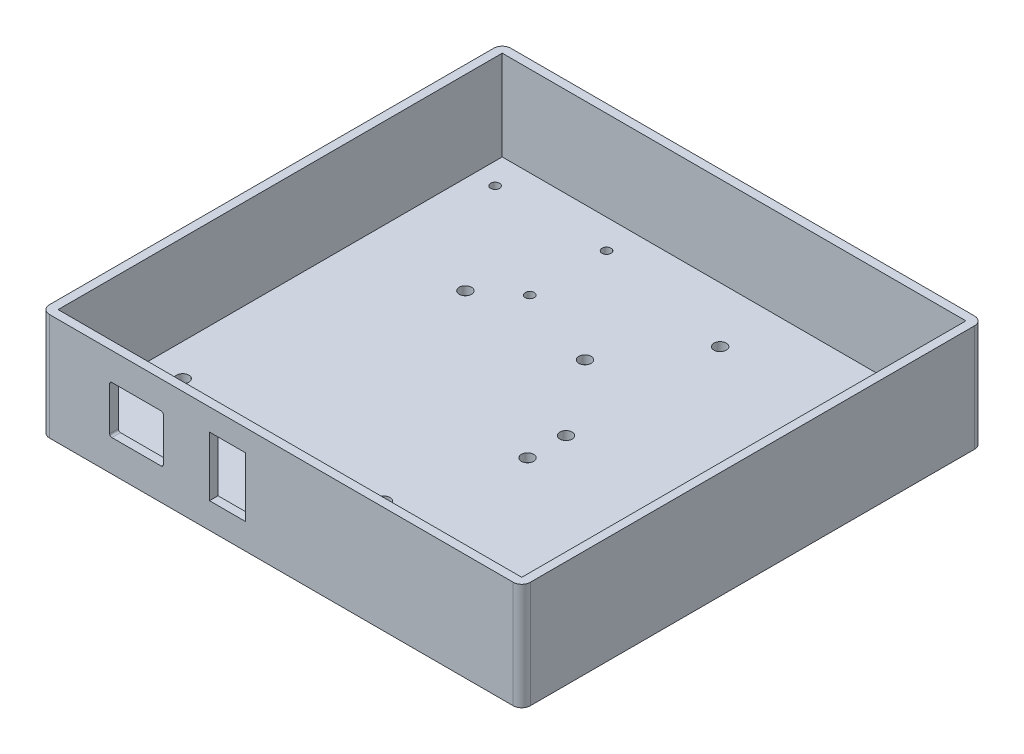
from build123d import *

# Parameters (mm, degrees)
SKETCH1_W           = 108.34
SKETCH1_H           = 103.78
BOSS_EXTRUDE1_DEPTH = 4
SKETCH2_W           = 112.34
SKETCH2_H           = 107.78
SKETCH2_W_2         = 108.34
SKETCH2_H_2         = 103.78
BOSS_EXTRUDE2_DEPTH = 25
SKETCH4_W           = 11.12
SKETCH4_H           = 9.75
CUT_EXTRUDE1_DEPTH  = 2
FILLET1_R           = 2
SKETCH5_R           = 1.4375
SKETCH5_R_2         = 1.05
CUT_EXTRUDE2_DEPTH  = 2
SKETCH6_W           = 8.4
SKETCH6_H           = 13.9
CUT_EXTRUDE3_DEPTH  = 2


with BuildPart() as part:
    # Sketch1 → Boss-Extrude1 (new body)
    with BuildSketch(Plane(origin=(0, 878.628416044, 0), x_dir=(1, 0, 0), z_dir=(0, 1, 0))):
        with Locations((715.681242052, -1282.120951231)):
            Rectangle(SKETCH1_W, SKETCH1_H)
    extrude(amount=-BOSS_EXTRUDE1_DEPTH)

    # Sketch5 → Cut-Extrude2 (cut)
    with BuildSketch(Plane(origin=(0, 878.628416044, 0), x_dir=(1, 0, 0), z_dir=(0, 1, 0))):
        with Locations(Location((684.291242052, -1261.620951231, 0), (0, 0, 270))):
            Circle(SKETCH5_R)
        with Locations(Location((666.521242052, -1236.910951231, 0), (0, 0, 270))):
            Circle(SKETCH5_R_2)
        with Locations(Location((692.681242052, -1237.030951231, 0), (0, 0, 270))):
            Circle(SKETCH5_R_2)
        with Locations(Location((692.681242052, -1254.970951231, 0), (0, 0, 270))):
            Circle(SKETCH5_R_2)
        with Locations(Location((712.231242052, -1261.620951231, 0), (0, 0, 270))):
            Circle(SKETCH5_R)
        with Locations(Location((725.351242052, -1243.160951231, 0), (0, 0, 270))):
            Circle(SKETCH5_R)
        with Locations(Location((761.351242052, -1243.160951231, 0), (0, 0, 270))):
            Circle(SKETCH5_R)
        with Locations(Location((725.351242052, -1279.160951231, 0), (0, 0, 270))):
            Circle(SKETCH5_R)
        with Locations(Location((761.351242052, -1279.160951231, 0), (0, 0, 270))):
            Circle(SKETCH5_R)
        with Locations(Location((761.351242052, -1288.160951231, 0), (0, 0, 270))):
            Circle(SKETCH5_R)
        with Locations(Location((725.351242052, -1288.160951231, 0), (0, 0, 270))):
            Circle(SKETCH5_R)
        with Locations(Location((761.351242052, -1324.160951231, 0), (0, 0, 270))):
            Circle(SKETCH5_R)
        with Locations(Location((725.351242052, -1324.160951231, 0), (0, 0, 270))):
            Circle(SKETCH5_R)
        with Locations(Location((717.311242052, -1313.690951231, 0), (0, 0, 270))):
            Circle(SKETCH5_R)
        with Locations(Location((669.051242052, -1312.420951231, 0), (0, 0, 270))):
            Circle(SKETCH5_R)
    extrude(amount=-CUT_EXTRUDE2_DEPTH, mode=Mode.SUBTRACT)


with BuildPart() as body_2:
    # Sketch2 → Boss-Extrude2 (new body)
    with BuildSketch(Plane(origin=(0, 874.628416044, 0), x_dir=(1, 0, 0), z_dir=(0, 1, 0))):
        with Locations((715.681242052, -1282.120951231)):
            Rectangle(SKETCH2_W, SKETCH2_H)
        with Locations((715.681242052, -1282.120951231)):
            Rectangle(SKETCH2_W_2, SKETCH2_H_2, mode=Mode.SUBTRACT)
    extrude(amount=BOSS_EXTRUDE2_DEPTH)

    # Sketch4 → Cut-Extrude1 (cut)
    with BuildSketch(Plane.XY.offset(1336.010951231)):
        with BuildLine():
            Line((687.591242052, 893.168416044), (676.071242052, 893.168416044))
            ThreePointArc((676.071242052, 893.168416044), (675.717688661, 893.021969435), (675.571242052, 892.668416044))
            Line((675.571242052, 892.668416044), (675.571242052, 882.518416044))
            ThreePointArc((675.571242052, 882.518416044), (675.717688661, 882.164862654), (676.071242052, 882.018416044))
            Line((676.071242052, 882.018416044), (687.591242052, 882.018416044))
            ThreePointArc((687.591242052, 882.018416044), (687.944795443, 882.164862654), (688.091242052, 882.518416044))
            Line((688.091242052, 882.518416044), (688.091242052, 892.668416044))
            ThreePointArc((688.091242052, 892.668416044), (687.944795443, 893.021969435), (687.591242052, 893.168416044))
        make_face()
        with Locations((681.831242052, 887.593416044)):
            Rectangle(SKETCH4_W, SKETCH4_H, mode=Mode.SUBTRACT)
        with Locations((681.831242052, 887.593416044)):
            Rectangle(SKETCH4_W, SKETCH4_H)
    extrude(amount=-CUT_EXTRUDE1_DEPTH, mode=Mode.SUBTRACT)

    # Fillet1
    fillet1_edges = [body_2.edges().sort_by_distance(p)[0] for p in [
        (771.851242052, 887.128416044, 1228.230951231),
        (659.511242052, 887.128416044, 1228.230951231),
        (659.511242052, 887.128416044, 1336.010951231),
        (771.851242052, 887.128416044, 1336.010951231),
    ]]
    fillet(fillet1_edges, radius=FILLET1_R)

    # Sketch6 → Cut-Extrude3 (cut)
    with BuildSketch(Plane.XY.offset(1336.010951231)):
        with Locations((703.091242052, 887.593416044)):
            Rectangle(SKETCH6_W, SKETCH6_H)
    extrude(amount=-CUT_EXTRUDE3_DEPTH, mode=Mode.SUBTRACT)


solid = Compound([part.part, body_2.part])
